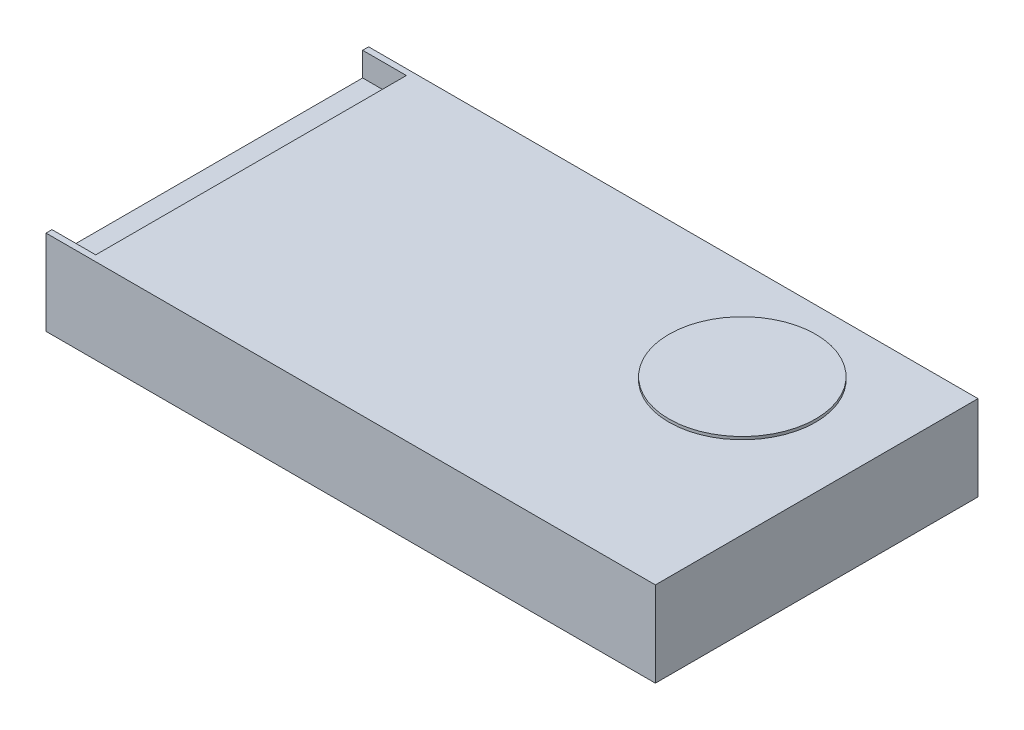
from build123d import *

# Parameters (mm, degrees)
SKETCH1_W           = 215.9
SKETCH1_H           = 114.3
BOSS_EXTRUDE1_DEPTH = 30.17
SKETCH2_W           = 15.5
SKETCH2_H           = 110.06
CUT_EXTRUDE1_DEPTH  = 8.5
SKETCH3_R           = 26
BOSS_EXTRUDE2_DEPTH = 1


with BuildPart() as part:
    # Sketch1 → Boss-Extrude1 (new body)
    with BuildSketch(Plane(origin=(0, 0, 0), x_dir=(1, 0, 0), z_dir=(0, 1, 0))):
        with Locations((107.95, 57.15)):
            Rectangle(SKETCH1_W, SKETCH1_H)
    extrude(amount=BOSS_EXTRUDE1_DEPTH)

    # Sketch2 → Cut-Extrude1 (cut)
    with BuildSketch(Plane(origin=(0, 30.17, 0), x_dir=(1, 0, 0), z_dir=(0, 1, 0))):
        with Locations((7.75, 57.15)):
            Rectangle(SKETCH2_W, SKETCH2_H)
    extrude(amount=-CUT_EXTRUDE1_DEPTH, mode=Mode.SUBTRACT)

    # Sketch3 → Boss-Extrude2 (add)
    with BuildSketch(Plane(origin=(0, 30.17, 0), x_dir=(1, 0, 0), z_dir=(0, 1, 0))):
        with Locations((168.4, 78.3)):
            Circle(SKETCH3_R)
    extrude(amount=BOSS_EXTRUDE2_DEPTH)


solid = part.part
